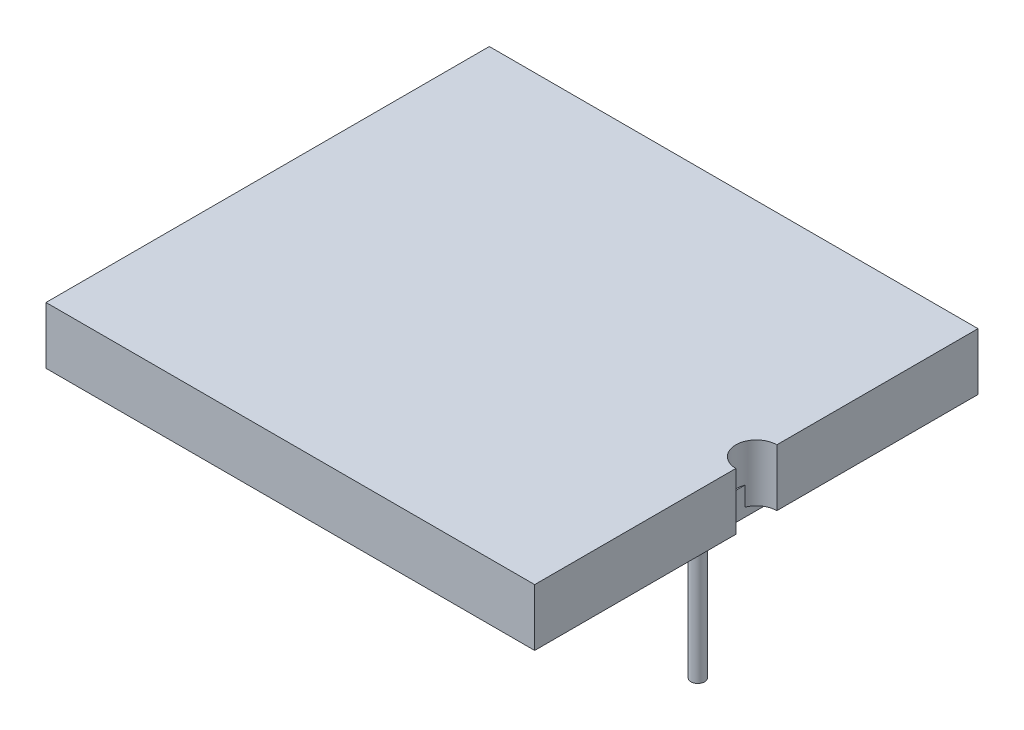
from build123d import *

# Parameters (mm, degrees)
BOSS_EXTRUDE1_DEPTH         = 1.95
SKETCH3_W                   = 10
SKETCH3_H                   = 10
BOSS_EXTRUDE6_DEPTH         = 1.05
SKETCH12_W                  = 15.4
SKETCH12_H                  = 14
BOSS_EXTRUDE11_DEPTH        = 0.3
BOSS_EXTRUDE11_DEPTH_BACK   = 0.65
SKETCH13_R                  = 0.5
BOSS_EXTRUDE12_DEPTH        = 0.3
BOSS_EXTRUDE12_TAPER        = 41
SKETCH14_R                  = 0.232885615
BOSS_EXTRUDE15_DEPTH        = 5
BOSS_EXTRUDE15_DEPTH_BACK   = 1.25
BOSS_EXTRUDE15_2_DEPTH      = 5
BOSS_EXTRUDE15_2_DEPTH_BACK = 1.25


with BuildPart() as part:
    # Sketch1 → Boss-Extrude1 (new body)
    with BuildSketch(Plane(origin=(0, 0, 0), x_dir=(1, 0, 0), z_dir=(0, 1, 0))):
        with BuildLine():
            Line((8.35, -0.7), (8.35, -7.575))
            Line((8.35, -7.575), (-8.35, -7.575))
            Line((-8.35, -7.575), (-8.35, 7.575))
            Line((-8.35, 7.575), (8.35, 7.575))
            Line((8.35, 7.575), (8.35, 0.7))
            ThreePointArc((8.35, 0.7), (7.65, 0), (8.35, -0.7))
        make_face()
    extrude(amount=-BOSS_EXTRUDE1_DEPTH)


with BuildPart() as body_2:
    # Sketch3 → Boss-Extrude6 (new body)
    with BuildSketch(Plane.XZ.offset(1.95)):
        Rectangle(SKETCH3_W, SKETCH3_H)
    extrude(amount=-BOSS_EXTRUDE6_DEPTH)


with BuildPart() as body_3:
    # Sketch12 → Boss-Extrude11 (new body, two sides)
    with BuildSketch(Plane.XZ.offset(1.95)) as boss_extrude11_sk:
        Rectangle(SKETCH12_W, SKETCH12_H)
    extrude(amount=BOSS_EXTRUDE11_DEPTH)
    extrude(boss_extrude11_sk.sketch, amount=-BOSS_EXTRUDE11_DEPTH_BACK)

    # Sketch13 → Boss-Extrude12 (add)
    with BuildSketch(Plane.XZ.offset(2.25)):
        with Locations((-6.35, 0)):
            Circle(SKETCH13_R)
        with Locations((6.35, 0)):
            Circle(SKETCH13_R)
    extrude(amount=BOSS_EXTRUDE12_DEPTH, taper=BOSS_EXTRUDE12_TAPER)


with BuildPart() as body_4:
    # Sketch14 → Boss-Extrude15 (new body, two sides)
    with BuildSketch(Plane.XZ.offset(2.55)) as boss_extrude15_sk:
        with Locations(Location((-6.35, 0, 0), (0, 0, 270))):  # turned: the seam where the file's is
            Circle(SKETCH14_R)
    extrude(amount=BOSS_EXTRUDE15_DEPTH)
    extrude(boss_extrude15_sk.sketch, amount=-BOSS_EXTRUDE15_DEPTH_BACK)


with BuildPart() as body_5:
    # Sketch14 → Boss-Extrude15 2 (new body, two sides)
    with BuildSketch(Plane.XZ.offset(2.55)) as boss_extrude15_2_sk:
        with Locations(Location((6.35, 0, 0), (0, 0, 270))):  # turned: the seam where the file's is
            Circle(SKETCH14_R)
    extrude(amount=BOSS_EXTRUDE15_2_DEPTH)
    extrude(boss_extrude15_2_sk.sketch, amount=-BOSS_EXTRUDE15_2_DEPTH_BACK)


solid = Compound([part.part, body_2.part, body_3.part, body_4.part, body_5.part])
